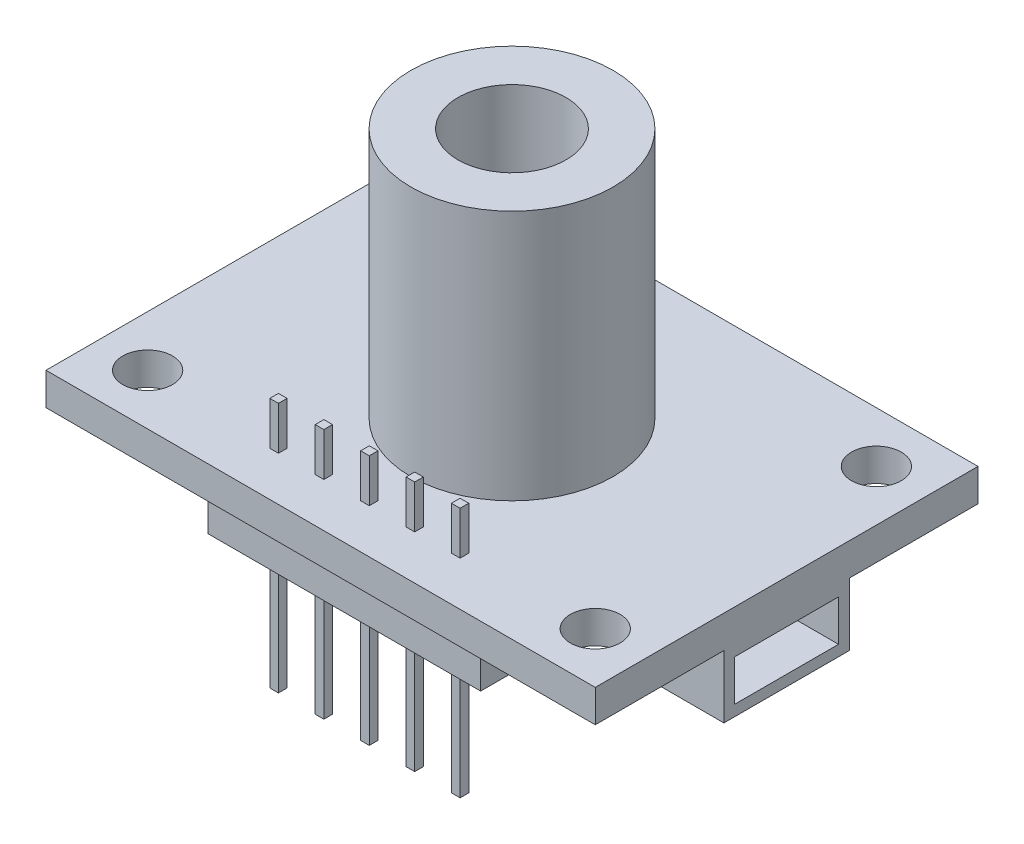
from build123d import *

# Parameters (mm, degrees)
SKETCH1_W                = 25.4
SKETCH1_H                = 17.7
SKETCH1_R                = 1.15
BOSS_EXTRUDE1_DEPTH      = 1.5
SKETCH2_R                = 4.675
BOSS_EXTRUDE2_DEPTH      = 11.6
SKETCH3_R                = 2.5
CUT_EXTRUDE1_DEPTH       = 8
SKETCH4_W                = 4
SKETCH4_H                = 5.8
BOSS_EXTRUDE3_DEPTH      = 2.9
SKETCH5_W                = 4.8
SKETCH5_H                = 1.9
CUT_EXTRUDE2_DEPTH       = 2.9
SKETCH6_W                = 12.6
SKETCH6_H                = 2.3
BOSS_EXTRUDE4_DEPTH      = 2.4
SKETCH7_W                = 0.4
SKETCH7_H                = 0.4
BOSS_EXTRUDE5_DEPTH      = 5.7
BOSS_EXTRUDE5_DEPTH_BACK = 5.9


with BuildPart() as part:
    # Sketch1 → Boss-Extrude1 (new body)
    with BuildSketch(Plane(origin=(0, 0, 0), x_dir=(1, 0, 0), z_dir=(0, 1, 0))):
        Rectangle(SKETCH1_W, SKETCH1_H)
        with Locations((10.35, 6.5)):
            Circle(SKETCH1_R, mode=Mode.SUBTRACT)
        with Locations((10.35, -6.5)):
            Circle(SKETCH1_R, mode=Mode.SUBTRACT)
        with Locations((-10.35, -6.5)):
            Circle(SKETCH1_R, mode=Mode.SUBTRACT)
        with Locations((-10.35, 6.5)):
            Circle(SKETCH1_R, mode=Mode.SUBTRACT)
    extrude(amount=BOSS_EXTRUDE1_DEPTH)

    # Sketch2 → Boss-Extrude2 (add)
    with BuildSketch(Plane(origin=(0, 1.5, 0), x_dir=(1, 0, 0), z_dir=(0, 1, 0))):
        Circle(SKETCH2_R)
    extrude(amount=BOSS_EXTRUDE2_DEPTH)

    # Sketch3 → Cut-Extrude1 (cut)
    with BuildSketch(Plane(origin=(0, 13.1, 0), x_dir=(1, 0, 0), z_dir=(0, 1, 0))):
        Circle(SKETCH3_R)
    extrude(amount=-CUT_EXTRUDE1_DEPTH, mode=Mode.SUBTRACT)

    # Sketch4 → Boss-Extrude3 (add)
    with BuildSketch(Plane.XZ):
        with Locations((10.7, 0)):
            Rectangle(SKETCH4_W, SKETCH4_H)
        with Locations((-10.7, 0)):
            Rectangle(SKETCH4_W, SKETCH4_H)
    extrude(amount=BOSS_EXTRUDE3_DEPTH)

    # Sketch5 → Cut-Extrude2 (cut)
    with BuildSketch(Plane(origin=(12.7, 0, 0), x_dir=(0, 0, -1), z_dir=(1, 0, 0))):
        with Locations((0, -1.45)):
            Rectangle(SKETCH5_W, SKETCH5_H)
    cut_extrude2 = extrude(amount=-CUT_EXTRUDE2_DEPTH, mode=Mode.SUBTRACT)

    # Mirror1: Cut-Extrude2 across plane
    add(cut_extrude2.mirror(Plane(origin=(0, 0, 0), x_dir=(0, 0, 1), z_dir=(1, 0, 0))), mode=Mode.SUBTRACT)

    # Sketch6 → Boss-Extrude4 (add)
    with BuildSketch(Plane.XZ):
        with Locations((0, 6.6)):
            Rectangle(SKETCH6_W, SKETCH6_H)
    extrude(amount=BOSS_EXTRUDE4_DEPTH)

    # Sketch7 → Boss-Extrude5 (add, two sides)
    with BuildSketch(Plane.XZ.offset(2.4)) as boss_extrude5_sk:
        with Locations((-4.2, 6.6)):
            Rectangle(SKETCH7_W, SKETCH7_H)
        with Locations((-2.1, 6.6)):
            Rectangle(SKETCH7_W, SKETCH7_H)
        with Locations((0, 6.6)):
            Rectangle(SKETCH7_W, SKETCH7_H)
        with Locations((2.1, 6.6)):
            Rectangle(SKETCH7_W, SKETCH7_H)
        with Locations((4.2, 6.6)):
            Rectangle(SKETCH7_W, SKETCH7_H)
    extrude(amount=BOSS_EXTRUDE5_DEPTH)
    extrude(boss_extrude5_sk.sketch, amount=-BOSS_EXTRUDE5_DEPTH_BACK)


solid = part.part
